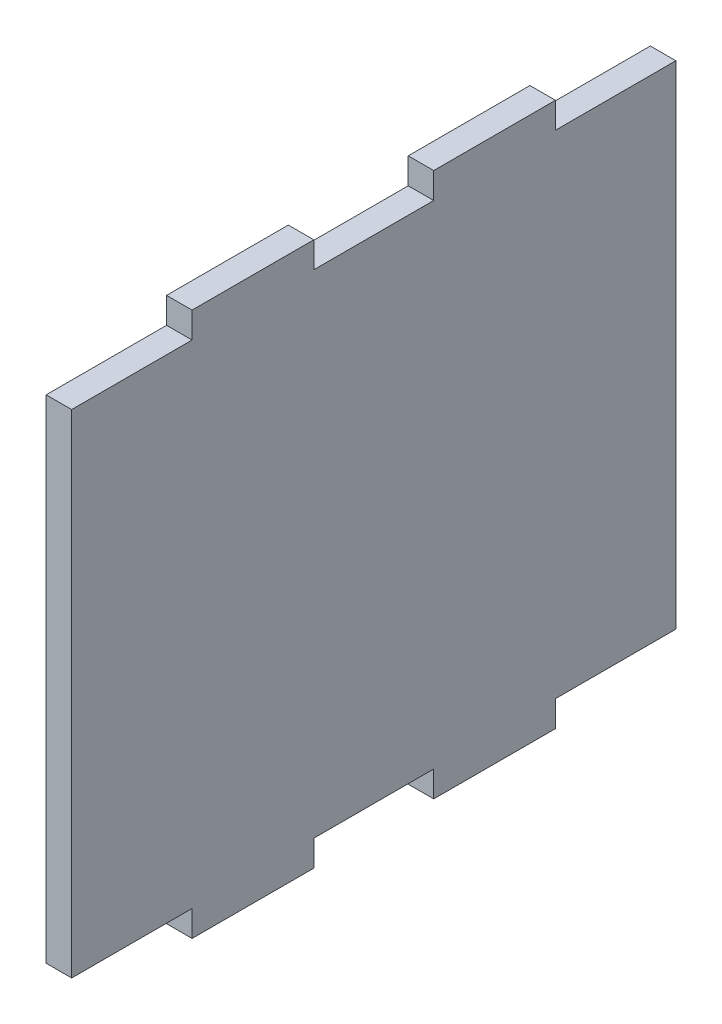
from build123d import *

# Parameters (mm, degrees)
SKETCH1_W           = 135
SKETCH1_H           = 122
BOSS_EXTRUDE1_DEPTH = 5.7
CUT_EXTRUDE1_DEPTH  = 57


with BuildPart() as part:
    # Sketch1 → Boss-Extrude1 (new body)
    with BuildSketch(Plane(origin=(0, 0, 0), x_dir=(0, 0, -1), z_dir=(1, 0, 0))):
        with Locations((67.5, 61)):
            Rectangle(SKETCH1_W, SKETCH1_H)
    extrude(amount=BOSS_EXTRUDE1_DEPTH)

    # Sketch2 → Cut-Extrude1 (cut)
    with BuildSketch(Plane(origin=(0, 0, 0), x_dir=(0, 0, -1), z_dir=(1, 0, 0))):
        Polygon((0, 116), (26.9, 116), (26.9, 121.8), (54.1, 121.8), (54.1, 116), (80.9, 116), (80.9, 121.8), (108.1, 121.8), (108.1, 116), (135, 116), (135, 130), (0, 130), align=None)
        Polygon((0, -8), (0, 6), (26.9, 6), (26.9, 0.2), (54.1, 0.2), (54.1, 6), (80.9, 6), (80.9, 0.2), (108.1, 0.2), (108.1, 6), (135, 6), (135, -8), align=None)
    extrude(amount=CUT_EXTRUDE1_DEPTH, mode=Mode.SUBTRACT)


solid = part.part
